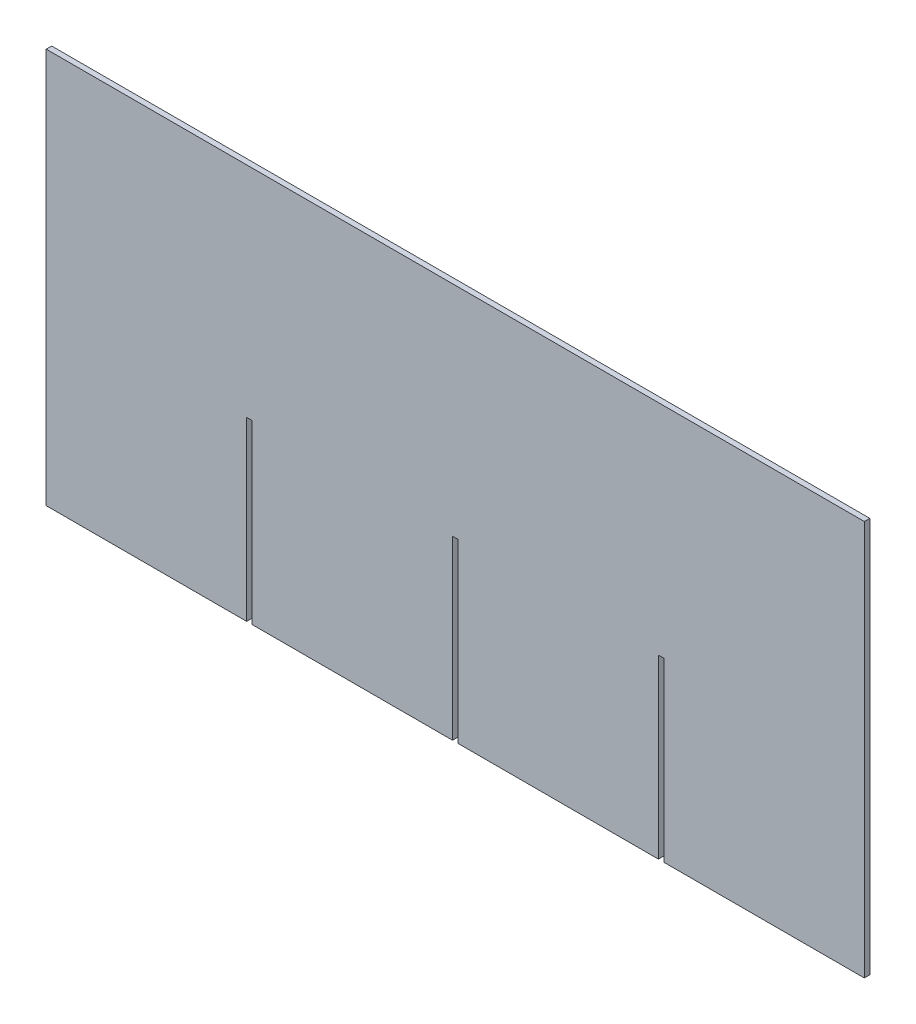
from build123d import *

# Parameters (mm, degrees)
BOSS_EXTRUDE1_DEPTH = 3


with BuildPart() as part:
    # Sketch1 → Boss-Extrude1 (new body)
    with BuildSketch(Plane.XY):
        Polygon((-113, 108.658536585), (336, 108.658536585), (336, -108.341463415), (226, -108.341463415), (226, -11.341463415), (223, -11.341463415), (223, -108.341463415), (113, -108.341463415), (113, -11.341463415), (110, -11.341463415), (110, -108.341463415), (0, -108.341463415), (0, -11.341463415), (-3, -11.341463415), (-3, -108.341463415), (-113, -108.341463415), align=None)
    extrude(amount=BOSS_EXTRUDE1_DEPTH)


solid = part.part
